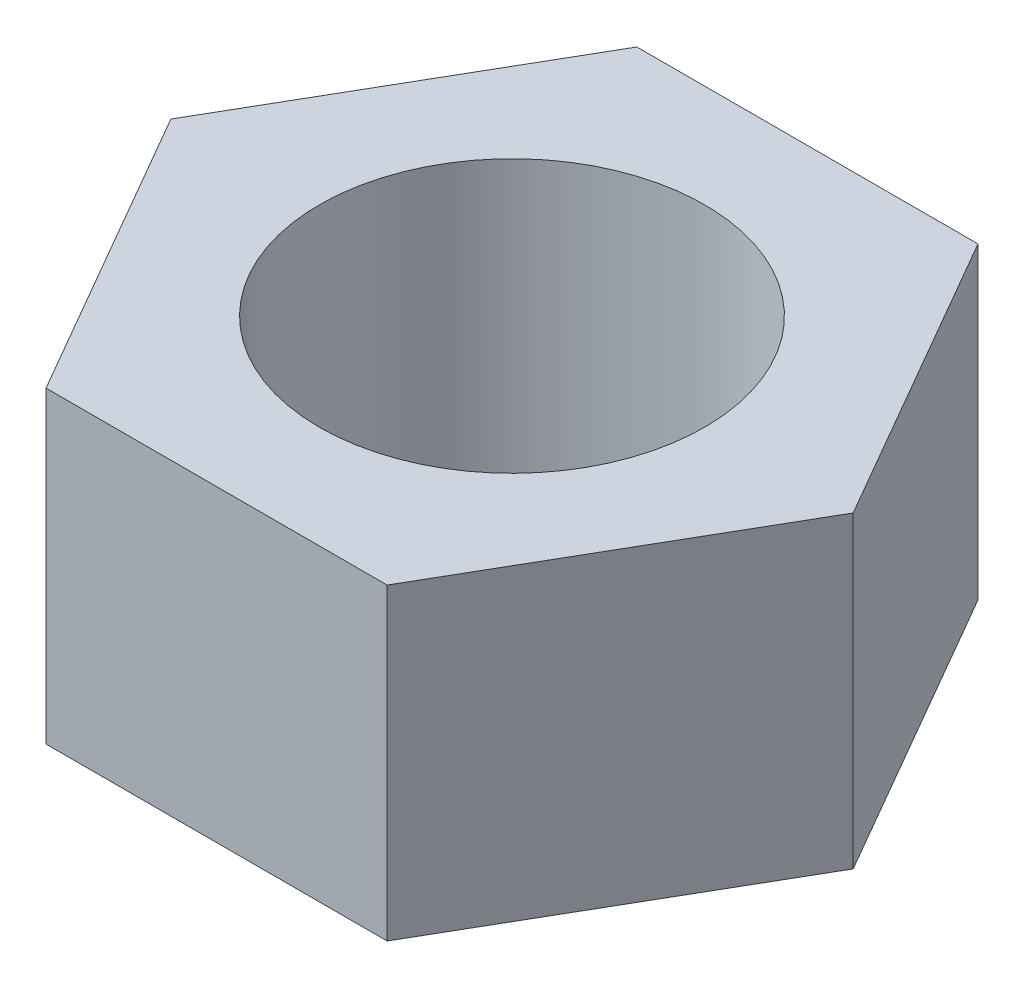
from build123d import *

# Parameters (mm, degrees)
BOSS_EXTRUDE1_DEPTH = 24
SKETCH2_R           = 15
CUT_EXTRUDE1_DEPTH  = 25


with BuildPart() as part:
    # Sketch1 → Boss-Extrude1 (new body)
    with BuildSketch(Plane(origin=(0, 0, 0), x_dir=(1, 0, 0), z_dir=(0, 1, 0))):
        Polygon((26.558112383, 0), (13.279056191, 23), (-13.279056191, 23), (-26.558112383, 0), (-13.279056191, -23), (13.279056191, -23), align=None)
    extrude(amount=BOSS_EXTRUDE1_DEPTH)

    # Sketch2 → Cut-Extrude1 (cut, through all)
    with BuildSketch(Plane(origin=(0, 24, 0), x_dir=(1, 0, 0), z_dir=(0, 1, 0))):
        Circle(SKETCH2_R)
    extrude(amount=-CUT_EXTRUDE1_DEPTH, mode=Mode.SUBTRACT)


solid = part.part
